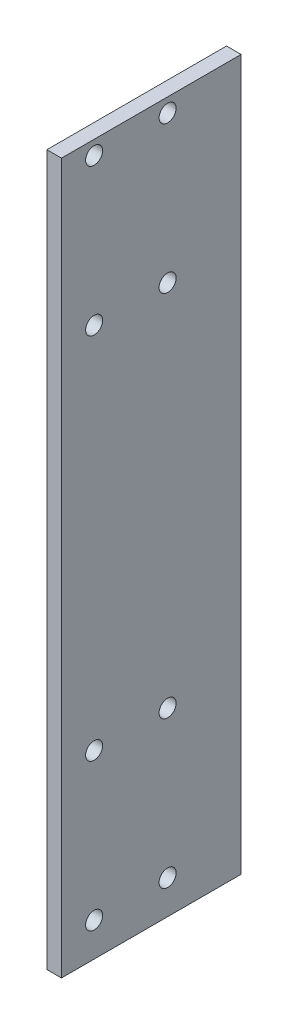
from build123d import *

# Parameters (mm, degrees)
SKETCH1_W           = 39.1132
SKETCH1_H           = 154.609070214
SKETCH1_R           = 1.8542
BOSS_EXTRUDE1_DEPTH = 3.175


with BuildPart() as part:
    # Sketch1 → Boss-Extrude1 (new body)
    with BuildSketch(Plane(origin=(0, 0, 0), x_dir=(0, 0, -1), z_dir=(1, 0, 0))):
        with Locations((-62.4434, 53.945464893)):
            Rectangle(SKETCH1_W, SKETCH1_H)
        with Locations((-74.8898, -16.000000004)):
            Circle(SKETCH1_R, mode=Mode.SUBTRACT)
        with Locations((-58.8898, -16.000000004)):
            Circle(SKETCH1_R, mode=Mode.SUBTRACT)
        with Locations((-74.8898, 16.000000004)):
            Circle(SKETCH1_R, mode=Mode.SUBTRACT)
        with Locations((-58.8898, 16.000000004)):
            Circle(SKETCH1_R, mode=Mode.SUBTRACT)
        with Locations((-74.8898, 128.200000004)):
            Circle(SKETCH1_R, mode=Mode.SUBTRACT)
        with Locations((-58.8898, 128.200000004)):
            Circle(SKETCH1_R, mode=Mode.SUBTRACT)
        with Locations((-74.8898, 96.199999996)):
            Circle(SKETCH1_R, mode=Mode.SUBTRACT)
        with Locations((-58.8898, 96.199999996)):
            Circle(SKETCH1_R, mode=Mode.SUBTRACT)
    extrude(amount=BOSS_EXTRUDE1_DEPTH)


solid = part.part
